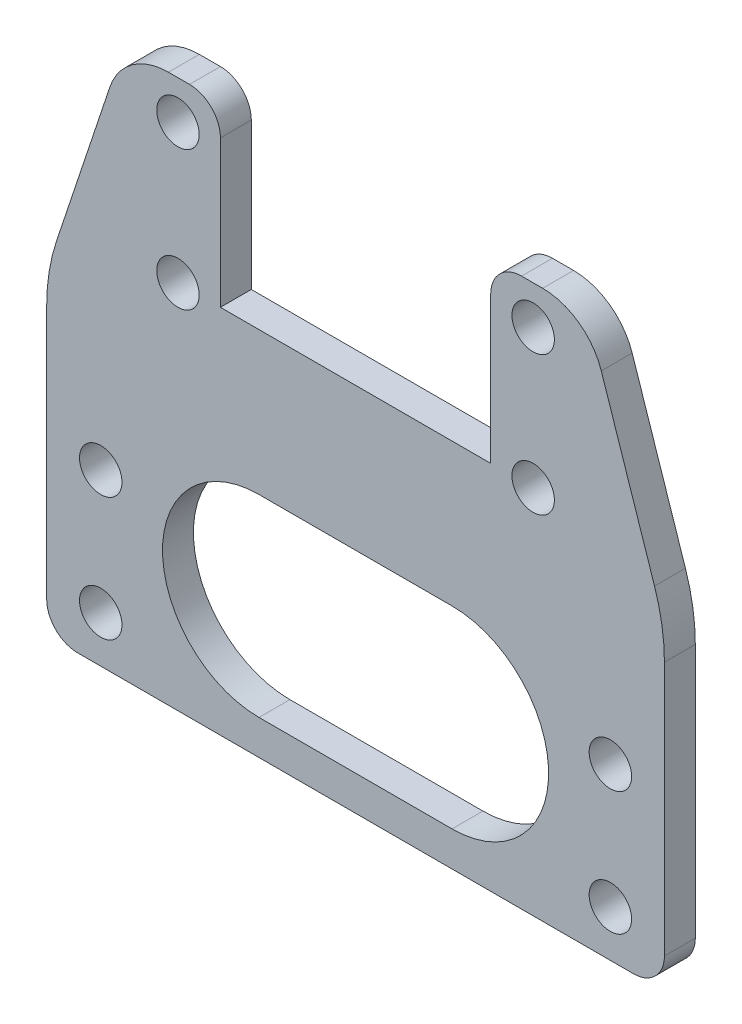
from build123d import *

# Parameters (mm, degrees)
SKETCH_1_R          = 2.75
EXTRUDE_1_DEPTH     = 4
SKETCH_2_R          = 2.75
EXTRUDE_2_DEPTH     = 4
FILLET_2_R          = 4
FILLET_3_R          = 8
FILLET_4_R          = 25
CUT_EXTRUDE_1_DEPTH = 5


with BuildPart() as part:
    # Эскиз1 → Бобышка-Вытянуть1 (new body)
    with BuildSketch(Plane.XY):
        Polygon((18, 0), (-18, 0), (-18, 23), (-30, 23), (-30, -7), (-40, -7), (-40, -32), (40, -32), (40, -7), (30, -7), (30, 23), (18, 23), align=None)
        with Locations((-23, 18)):
            Circle(SKETCH_1_R, mode=Mode.SUBTRACT)
        with Locations((-23, 0)):
            Circle(SKETCH_1_R, mode=Mode.SUBTRACT)
        with Locations((-33, -26)):
            Circle(SKETCH_1_R, mode=Mode.SUBTRACT)
        with Locations((0, -26)):
            Circle(SKETCH_1_R, mode=Mode.SUBTRACT)
        with Locations((33, -26)):
            Circle(SKETCH_1_R, mode=Mode.SUBTRACT)
        with Locations((23, 18)):
            Circle(SKETCH_1_R, mode=Mode.SUBTRACT)
        with Locations((23, 0)):
            Circle(SKETCH_1_R, mode=Mode.SUBTRACT)
    extrude(amount=EXTRUDE_1_DEPTH)

    # Эскиз2 → Бобышка-Вытянуть2 (add)
    with BuildSketch(Plane.XY):
        Polygon((17.5, 0), (-17.5, 0), (-17.5, 23), (-30, 23), (-40, -7), (-40, -32), (-40, -48), (40, -48), (40, -32), (40, -7), (30, 23), (17.5, 23), align=None)
        with Locations((-23, 18)):
            Circle(SKETCH_2_R, mode=Mode.SUBTRACT)
        with Locations((-23, 0)):
            Circle(SKETCH_2_R, mode=Mode.SUBTRACT)
        with Locations((-33, -26)):
            Circle(SKETCH_2_R, mode=Mode.SUBTRACT)
        with Locations((-33, -42)):
            Circle(SKETCH_2_R, mode=Mode.SUBTRACT)
        with Locations((33, -26)):
            Circle(SKETCH_2_R, mode=Mode.SUBTRACT)
        with Locations((23, 18)):
            Circle(SKETCH_2_R, mode=Mode.SUBTRACT)
        with Locations((23, 0)):
            Circle(SKETCH_2_R, mode=Mode.SUBTRACT)
        with Locations((33, -42)):
            Circle(SKETCH_2_R, mode=Mode.SUBTRACT)
    extrude(amount=EXTRUDE_2_DEPTH)

    # Скругление2
    fillet_2_edges = [part.edges().sort_by_distance(p)[0] for p in [
        (-17.5, 23, 2),
        (40, -48, 2),
        (-40, -48, 2),
        (17.5, 23, 2),
    ]]
    fillet(fillet_2_edges, radius=FILLET_2_R)

    # Скругление3
    fillet_3_edges = [part.edges().sort_by_distance(p)[0] for p in [
        (30, 23, 2),
        (-30, 23, 2),
    ]]
    fillet(fillet_3_edges, radius=FILLET_3_R)

    # Скругление4
    fillet_4_edges = [part.edges().sort_by_distance(p)[0] for p in [
        (40, -7, 2),
        (-40, -7, 2),
    ]]
    fillet(fillet_4_edges, radius=FILLET_4_R)

    # Эскиз3 → Вырез-Вытянуть1 (cut, through all)
    with BuildSketch(Plane.XY.offset(4)):
        with BuildLine():
            Line((-12.5, -18.5), (12.5, -18.5))
            ThreePointArc((12.5, -18.5), (25, -31), (12.5, -43.5))
            Line((12.5, -43.5), (-12.5, -43.5))
            ThreePointArc((-12.5, -43.5), (-25, -31), (-12.5, -18.5))
        make_face()
    extrude(amount=-CUT_EXTRUDE_1_DEPTH, mode=Mode.SUBTRACT)


solid = part.part
